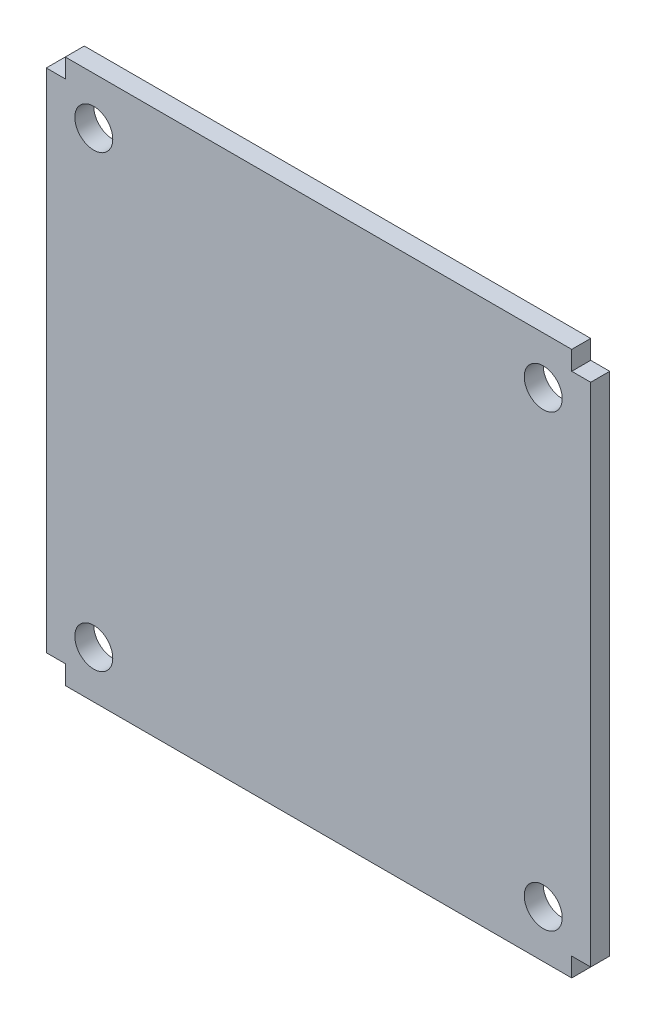
from build123d import *

# Parameters (mm, degrees)
SKETCH1_R           = 3
BOSS_EXTRUDE1_DEPTH = 3


with BuildPart() as part:
    # Sketch1 → Boss-Extrude1 (new body)
    with BuildSketch(Plane.XY):
        Polygon((-10.638145624, 32.976580824), (-10.638145624, 29.976580824), (-13.638145624, 29.976580824), (-13.638145624, -50.023419176), (-10.638145624, -50.023419176), (-10.638145624, -53.023419176), (69.361854376, -53.023419176), (69.361854376, -50.023419176), (72.361854376, -50.023419176), (72.361854376, 29.976580824), (69.361854376, 29.976580824), (69.361854376, 32.976580824), align=None)
        with Locations((-6.138145624, 25.476580824)):
            Circle(SKETCH1_R, mode=Mode.SUBTRACT)
        with Locations((64.861854376, 25.476580824)):
            Circle(SKETCH1_R, mode=Mode.SUBTRACT)
        with Locations((-6.138145624, -45.523419176)):
            Circle(SKETCH1_R, mode=Mode.SUBTRACT)
        with Locations((64.861854376, -45.523419176)):
            Circle(SKETCH1_R, mode=Mode.SUBTRACT)
    extrude(amount=BOSS_EXTRUDE1_DEPTH)


solid = part.part
